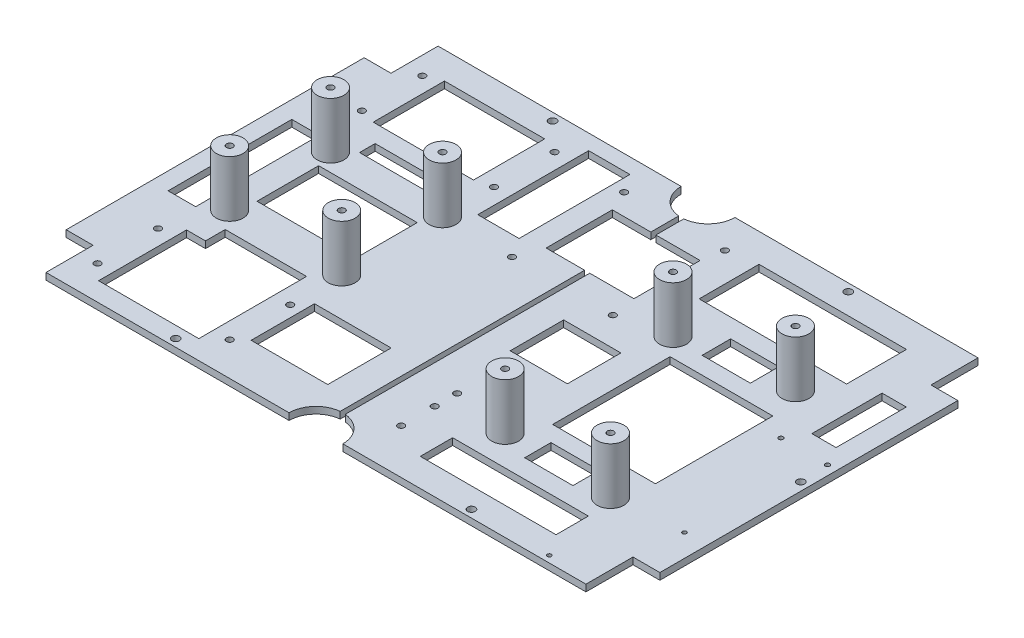
from build123d import *

# Parameters (mm, degrees)
SKETCH1_W           = 265
SKETCH1_H           = 175
BOSS_EXTRUDE3_DEPTH = 3
SKETCH2_R           = 1.45
CUT_EXTRUDE1_DEPTH  = 10
SKETCH3_R           = 1.7
CUT_EXTRUDE2_DEPTH  = 10
SKETCH4_R           = 12
SKETCH4_W           = 12
SKETCH4_H           = 21
CUT_EXTRUDE3_DEPTH  = 10
SKETCH5_R           = 6
BOSS_EXTRUDE4_DEPTH = 25
SKETCH6_R           = 1.45
CUT_EXTRUDE4_DEPTH  = 16
SKETCH7_W           = 2.28277186
SKETCH7_H           = 151.108810146
CUT_EXTRUDE5_DEPTH  = 16
SKETCH8_W           = 44.004051782
SKETCH8_H           = 27.502532364
SKETCH8_W_2         = 12.303764479
SKETCH8_H_2         = 55.212044537
SKETCH8_W_3         = 44.752484312
SKETCH8_H_3         = 31.794399539
SKETCH8_W_4         = 18.417789402
SKETCH8_H_4         = 49.48036565
SKETCH8_W_5         = 35.622307927
SKETCH8_H_5         = 6.958328597
SKETCH8_W_6         = 34.203626282
SKETCH8_H_6         = 28.27990646
SKETCH8_W_7         = 39.195026094
SKETCH8_H_7         = 29.538035132
CUT_EXTRUDE6_DEPTH  = 10
SKETCH9_R           = 6.000002307
SKETCH9_R_2         = 6
BOSS_EXTRUDE5_DEPTH = 25
SKETCH10_R          = 1.45
CUT_EXTRUDE7_DEPTH  = 15
SKETCH11_R          = 0.9
SKETCH11_R_2        = 1
CUT_EXTRUDE8_DEPTH  = 20
SKETCH12_W          = 65.824644824
SKETCH12_H          = 26.741508741
SKETCH12_W_2        = 45.872902753
SKETCH12_H_2        = 52.394050694
SKETCH12_W_3        = 25.550647508
SKETCH12_H_3        = 23.884300932
SKETCH12_W_4        = 60.583146779
SKETCH12_H_4        = 14.424558757
SKETCH12_W_5        = 10.797203955
SKETCH12_H_5        = 31.33906792
SKETCH12_W_6        = 21.530984019
SKETCH12_H_6        = 12.727284746
SKETCH12_H_7        = 11.735628575
CUT_EXTRUDE9_DEPTH  = 20


with BuildPart() as part:
    # Sketch1 → Boss-Extrude3 (new body)
    with BuildSketch(Plane(origin=(0, 0, 0), x_dir=(1, 0, 0), z_dir=(0, 1, 0))):
        Rectangle(SKETCH1_W, SKETCH1_H)
    extrude(amount=BOSS_EXTRUDE3_DEPTH)

    # Sketch2 → Cut-Extrude1 (cut)
    with BuildSketch(Plane(origin=(0, 3, 0), x_dir=(1, 0, 0), z_dir=(0, 1, 0))):
        with Locations((18, -67.5)):
            Circle(SKETCH2_R)
        with Locations((18, -52.5)):
            Circle(SKETCH2_R)
        with Locations((18, -42.5)):
            Circle(SKETCH2_R)
        with Locations((18, -27.5)):
            Circle(SKETCH2_R)
        with Locations((-53.5, -72.5)):
            Circle(SKETCH2_R)
        with Locations((-53.5, -45.5)):
            Circle(SKETCH2_R)
        with Locations((-112.5, -45.5)):
            Circle(SKETCH2_R)
        with Locations((-112.5, -72.5)):
            Circle(SKETCH2_R)
        with Locations((-112.5, 45.5)):
            Circle(SKETCH2_R)
        with Locations((-53.5, 45.5)):
            Circle(SKETCH2_R)
        with Locations((-53.5, 72.5)):
            Circle(SKETCH2_R)
        with Locations((-112.5, 72.5)):
            Circle(SKETCH2_R)
        with Locations((-22.5, 22.5)):
            Circle(SKETCH2_R)
        with Locations((22.5, 22.5)):
            Circle(SKETCH2_R)
        with Locations((-22.5, 72.5)):
            Circle(SKETCH2_R)
        with Locations((22.5, 72.5)):
            Circle(SKETCH2_R)
    extrude(amount=-CUT_EXTRUDE1_DEPTH, mode=Mode.SUBTRACT)

    # Sketch3 → Cut-Extrude2 (cut)
    with BuildSketch(Plane(origin=(0, 3, 0), x_dir=(1, 0, 0), z_dir=(0, 1, 0))):
        with Locations((-66, 84.1)):
            Circle(SKETCH3_R)
        with Locations((-128.9, 0)):
            Circle(SKETCH3_R)
        with Locations((-66, -84.1)):
            Circle(SKETCH3_R)
        with Locations((66, -84.1)):
            Circle(SKETCH3_R)
        with Locations((66, 84.1)):
            Circle(SKETCH3_R)
        with Locations((128.9, 0)):
            Circle(SKETCH3_R)
    extrude(amount=-CUT_EXTRUDE2_DEPTH, mode=Mode.SUBTRACT)

    # Sketch4 → Cut-Extrude3 (cut)
    with BuildSketch(Plane(origin=(0, 3, 0), x_dir=(1, 0, 0), z_dir=(0, 1, 0))):
        with Locations((0, 87.5)):
            Circle(SKETCH4_R)
        with Locations((0, -87.5)):
            Circle(SKETCH4_R)
        with Locations((-126.5, 77)):
            Rectangle(SKETCH4_W, SKETCH4_H)
        with Locations((-126.5, -77)):
            Rectangle(SKETCH4_W, SKETCH4_H)
        with Locations((126.5, -77)):
            Rectangle(SKETCH4_W, SKETCH4_H)
        with Locations((126.5, 77)):
            Rectangle(SKETCH4_W, SKETCH4_H)
    extrude(amount=-CUT_EXTRUDE3_DEPTH, mode=Mode.SUBTRACT)

    # Sketch5 → Boss-Extrude4 (add)
    with BuildSketch(Plane(origin=(0, 3, 0), x_dir=(1, 0, 0), z_dir=(0, 1, 0))):
        with Locations((-53.5, 22.5)):
            Circle(SKETCH5_R)
        with Locations((-53.5, -22.5)):
            Circle(SKETCH5_R)
        with Locations((-103.5, -22.5)):
            Circle(SKETCH5_R)
        with Locations((-103.5, 22.5)):
            Circle(SKETCH5_R)
    extrude(amount=BOSS_EXTRUDE4_DEPTH)

    # Sketch6 → Cut-Extrude4 (cut)
    with BuildSketch(Plane(origin=(0, 28, 0), x_dir=(1, 0, 0), z_dir=(0, 1, 0))):
        with Locations((-103.5, 22.5)):
            Circle(SKETCH6_R)
        with Locations((-53.5, 22.5)):
            Circle(SKETCH6_R)
        with Locations((-53.5, -22.5)):
            Circle(SKETCH6_R)
        with Locations((-103.5, -22.5)):
            Circle(SKETCH6_R)
    extrude(amount=-CUT_EXTRUDE4_DEPTH, mode=Mode.SUBTRACT)

    # Sketch7 → Cut-Extrude5 (cut)
    with BuildSketch(Plane(origin=(0, 3, 0), x_dir=(1, 0, 0), z_dir=(0, 1, 0))):
        Rectangle(SKETCH7_W, SKETCH7_H)
    extrude(amount=-CUT_EXTRUDE5_DEPTH, mode=Mode.SUBTRACT)

    # Sketch8 → Cut-Extrude6 (cut)
    with BuildSketch(Plane(origin=(0, 3, 0), x_dir=(1, 0, 0), z_dir=(0, 1, 0))):
        with Locations((-78.918320173, 0.855666755)):
            Rectangle(SKETCH8_W, SKETCH8_H)
        with Locations((-118.65224193, -1.087828844)):
            Rectangle(SKETCH8_W_2, SKETCH8_H_2)
        with Locations((-83.191731608, 59.522375806)):
            Rectangle(SKETCH8_W_3, SKETCH8_H_3)
        with Locations((-37.255467463, 55.937928823)):
            Rectangle(SKETCH8_W_4, SKETCH8_H_4)
        with Locations((-79.05742687, 32.298336537)):
            Rectangle(SKETCH8_W_5, SKETCH8_H_5)
        Polygon((-105.567973764, -39.71130787), (-105.567973764, -78.974026671), (-60.815489452, -78.974026671), (-60.815489452, -30.899446131), (-97.101226796, -30.899446131), (-97.101226796, -39.71130787), align=None)
        with Locations((-31.38483974, -53.81421566)):
            Rectangle(SKETCH8_W_6, SKETCH8_H_6)
        with Locations((1.26798102, 48.327638245)):
            Rectangle(SKETCH8_W_7, SKETCH8_H_7)
    extrude(amount=-CUT_EXTRUDE6_DEPTH, mode=Mode.SUBTRACT)

    # Sketch9 → Boss-Extrude5 (add)
    with BuildSketch(Plane(origin=(0, 3, 0), x_dir=(1, 0, 0), z_dir=(0, 1, 0))):
        with Locations((92.5, -48.53)):
            Circle(SKETCH9_R)
        with Locations((44.2, -47.26)):
            Circle(SKETCH9_R_2)
        with Locations((92.5, 34.02)):
            Circle(SKETCH9_R_2)
        with Locations((44.2, 27.67)):
            Circle(SKETCH9_R_2)
    extrude(amount=BOSS_EXTRUDE5_DEPTH)

    # Sketch10 → Cut-Extrude7 (cut)
    with BuildSketch(Plane(origin=(0, 28, 0), x_dir=(1, 0, 0), z_dir=(0, 1, 0))):
        with Locations((44.2, 27.67)):
            Circle(SKETCH10_R)
        with Locations((92.5, 34.02)):
            Circle(SKETCH10_R)
        with Locations((44.2, -47.26)):
            Circle(SKETCH10_R)
        with Locations((92.5, -48.53)):
            Circle(SKETCH10_R)
    extrude(amount=-CUT_EXTRUDE7_DEPTH, mode=Mode.SUBTRACT)

    # Sketch11 → Cut-Extrude8 (cut)
    with BuildSketch(Plane(origin=(0, 3, 0), x_dir=(1, 0, 0), z_dir=(0, 1, 0))):
        with Locations((122.5, -45.53)):
            Circle(SKETCH11_R)
        with Locations((101.2, -84.53)):
            Circle(SKETCH11_R)
        with Locations((107.5, 12.52)):
            Circle(SKETCH11_R_2)
        with Locations((128.3, 12.52)):
            Circle(SKETCH11_R_2)
    extrude(amount=-CUT_EXTRUDE8_DEPTH, mode=Mode.SUBTRACT)

    # Sketch12 → Cut-Extrude9 (cut)
    with BuildSketch(Plane(origin=(0, 3, 0), x_dir=(1, 0, 0), z_dir=(0, 1, 0))):
        with Locations((68.390389781, 61.406582632)):
            Rectangle(SKETCH12_W, SKETCH12_H)
        with Locations((74.273491824, -6.977727675)):
            Rectangle(SKETCH12_W_2, SKETCH12_H_2)
        with Locations((26.146563523, -2.256498378)):
            Rectangle(SKETCH12_W_3, SKETCH12_H_3)
        with Locations((64.422968154, -67.847935803)):
            Rectangle(SKETCH12_W_4, SKETCH12_H_4)
        with Locations((118.129683067, 36.789648858)):
            Rectangle(SKETCH12_W_5, SKETCH12_H_5)
        with Locations((68.732983789, 33.256074077)):
            Rectangle(SKETCH12_W_6, SKETCH12_H_6)
        with Locations((68.732983789, -46.43401065)):
            Rectangle(SKETCH12_W_6, SKETCH12_H_7)
    extrude(amount=-CUT_EXTRUDE9_DEPTH, mode=Mode.SUBTRACT)


solid = part.part
